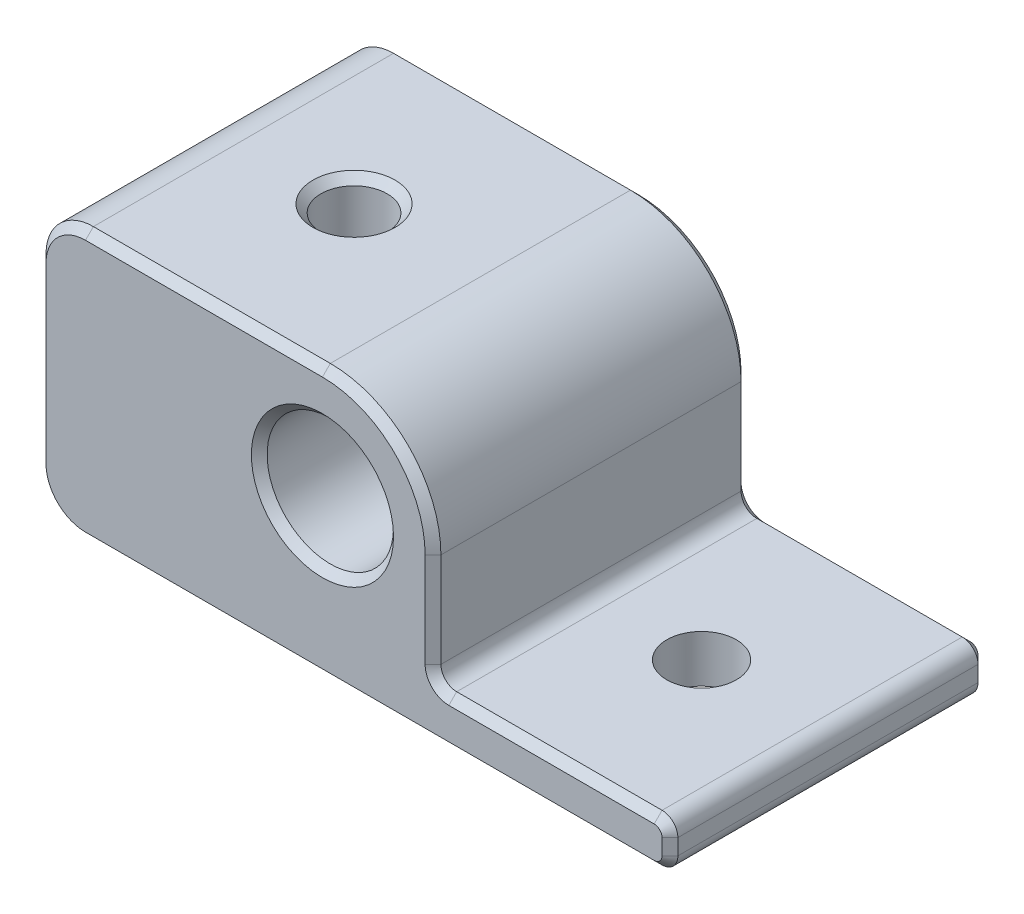
from build123d import *

# Parameters (mm, degrees)
SKETCH1_W                      = 40
SKETCH1_H                      = 20
BOSS_EXTRUDE1_DEPTH            = 17
SKETCH2_W                      = 15
SKETCH2_H                      = 14
CUT_EXTRUDE1_DEPTH             = 21
F_4_4_4_4_DIAMETER_HOLE1_D     = 4.4
F_4_4_4_4_DIAMETER_HOLE1_DEPTH = 17
F_4_2_4_2_DIAMETER_HOLE1_D     = 4.2
F_4_2_4_2_DIAMETER_HOLE1_DEPTH = 17
FILLET1_R                      = 1
FILLET2_R                      = 3
FILLET3_R                      = 7
CHAMFER1_SIZE                  = 0.5


with BuildPart() as part:
    # Sketch1 → Boss-Extrude1 (new body)
    with BuildSketch(Plane.XZ.offset(4.571066784)):
        with Locations((39.501752658, 9.570440181)):
            Rectangle(SKETCH1_W, SKETCH1_H)
    extrude(amount=-BOSS_EXTRUDE1_DEPTH)

    # Sketch2 → Cut-Extrude1 (cut, through all)
    with BuildSketch(Plane.XY.offset(19.570440181)):
        with Locations((52.001752658, 5.428933216)):
            Rectangle(SKETCH2_W, SKETCH2_H)
    extrude(amount=-CUT_EXTRUDE1_DEPTH, mode=Mode.SUBTRACT)

    # Ø4.4 (4.4) Diameter Hole1
    with Locations(Plane(origin=(0, -4.571066784, 0), x_dir=(-1, 0, 0), z_dir=(0, -1, 0))):
        with Locations((-51.501752658, -9.570440181)):
            Hole(F_4_4_4_4_DIAMETER_HOLE1_D / 2, depth=F_4_4_4_4_DIAMETER_HOLE1_DEPTH)

    # Ø4.2 (4.2) Diameter Hole1
    with Locations(Plane(origin=(0, 12.428933216, 0), x_dir=(1, 0, 0), z_dir=(0, 1, 0))):
        with Locations((29.501752658, -9.570440181)):
            Hole(F_4_2_4_2_DIAMETER_HOLE1_D / 2, depth=F_4_2_4_2_DIAMETER_HOLE1_DEPTH)

    # Sketch7 → Hole1 (revolve, cut)
    with BuildSketch(Plane(origin=(37.501752658, 5.428933216, 19.570440181), x_dir=(0, -1, 0), z_dir=(1, 0, 0))):
        Polygon((0, 0), (0, 20), (3, 20), (3, 19), (4, 18), (4, 0), align=None)
    revolve(axis=Axis((37.501752658, 5.428933216, 25.70046408), (0, 0, -1)), mode=Mode.SUBTRACT)

    # Fillet1
    fillet1_edges = [part.edges().sort_by_distance(p)[0] for p in [
        (59.501752658, -1.571066784, 9.570440181),
        (44.501752658, -1.571066784, 9.570440181),
        (59.501752658, -4.571066784, 9.570440181),
    ]]
    fillet(fillet1_edges, radius=FILLET1_R)

    # Fillet2
    fillet2_edges = [part.edges().sort_by_distance(p)[0] for p in [
        (19.501752658, 12.428933216, 9.570440181),
        (19.501752658, -4.571066784, 9.570440181),
    ]]
    fillet(fillet2_edges, radius=FILLET2_R)

    # Fillet3
    fillet3_edges = [part.edges().sort_by_distance(p)[0] for p in [
        (44.501752658, 12.428933216, 9.570440181),
    ]]
    fillet(fillet3_edges, radius=FILLET3_R)

    # Chamfer1
    chamfer1_edges = [part.edges().sort_by_distance(p)[0] for p in [
        (31.601752658, 12.428933216, 9.570440181),
        (31.601752658, -4.571066784, 9.570440181),
        (37.501752658, 9.428933216, 19.570440181),
        (52.001752658, -1.571066784, 19.570440181),
        (52.001752658, -1.571066784, -0.429559819),
        (59.501752658, -3.071066784, 19.570440181),
        (59.501752658, -3.071066784, -0.429559819),
        (40.501752658, -4.571066784, 19.570440181),
        (59.208859439, -4.278173565, 19.570440181),
        (59.208859439, -1.863960002, 19.570440181),
        (59.208859439, -4.278173565, -0.429559819),
        (59.208859439, -1.863960002, -0.429559819),
        (44.794645876, -1.278173565, 19.570440181),
        (44.794645876, -1.278173565, -0.429559819),
        (40.501752658, -4.571066784, -0.429559819),
        (19.501752658, 3.928933216, -0.429559819),
        (30.001752658, 12.428933216, -0.429559819),
        (20.380432314, 11.55025356, -0.429559819),
        (20.380432314, -3.692387127, -0.429559819),
        (19.501752658, 3.928933216, 19.570440181),
        (20.380432314, 11.55025356, 19.570440181),
        (20.380432314, -3.692387127, 19.570440181),
        (44.501752658, 2.428933216, 19.570440181),
        (44.501752658, 2.428933216, -0.429559819),
        (30.001752658, 12.428933216, 19.570440181),
        (42.451500126, 10.378680685, 19.570440181),
        (42.451500126, 10.378680685, -0.429559819),
    ]]
    chamfer(chamfer1_edges, length=CHAMFER1_SIZE)


solid = part.part
